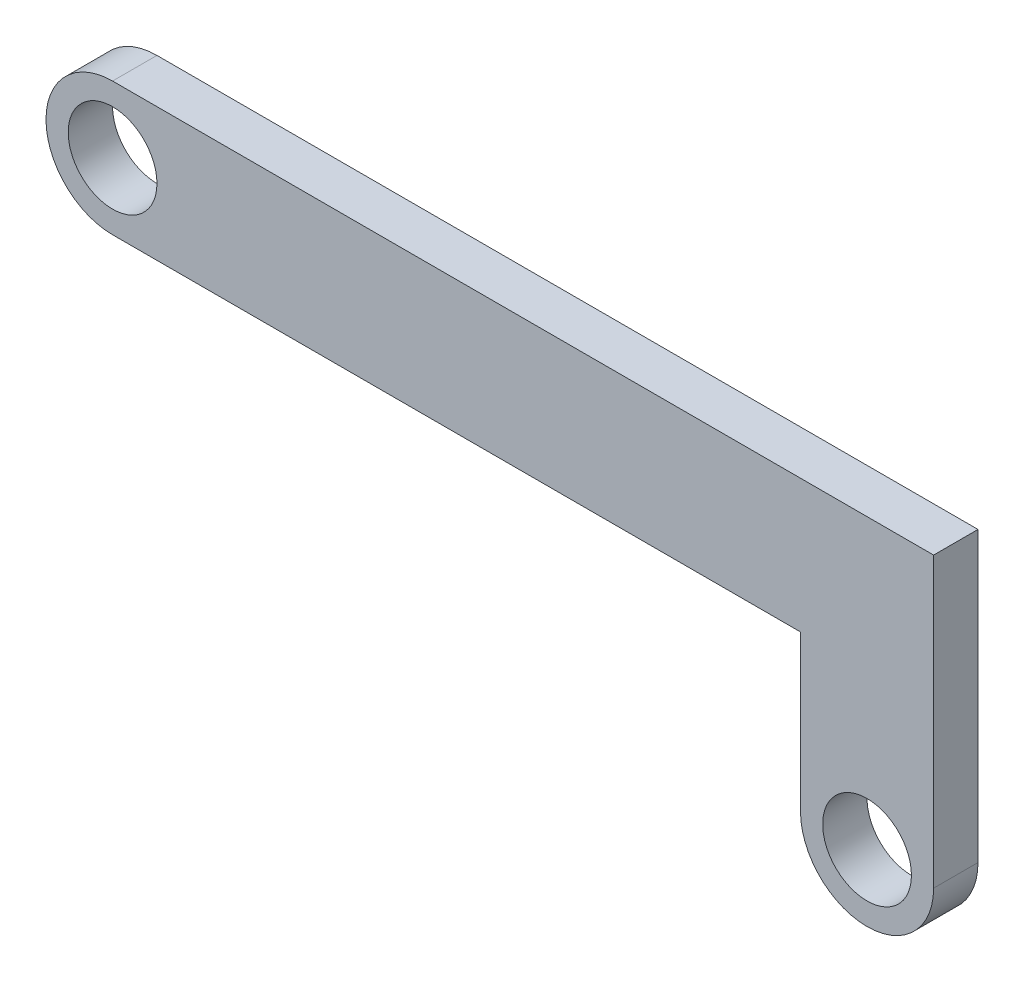
from build123d import *

# Parameters (mm, degrees)
BOSS_EXTRUDE1_DEPTH = 5
SKETCH2_R           = 5
CUT_EXTRUDE1_DEPTH  = 5


with BuildPart() as part:
    # Sketch1 → Boss-Extrude1 (new body)
    with BuildSketch(Plane.XY):
        Polygon((-73.283312465, -1.804635762), (26.716687535, -1.804635762), (26.716687535, -41.804635762), (11.716687535, -41.804635762), (11.716687535, -16.804635762), (-73.283312465, -16.804635762), align=None)
    extrude(amount=BOSS_EXTRUDE1_DEPTH)

    # Sketch2 → Cut-Extrude1 (cut)
    with BuildSketch(Plane.XY.offset(5)):
        with Locations((19.216687535, -34.304635762)):
            Circle(SKETCH2_R)
        with BuildLine():
            ThreePointArc((19.216687535, -41.804635762), (13.913386676, -39.60793662), (11.716687535, -34.304635762))
            Line((11.716687535, -34.304635762), (11.716687535, -41.804635762))
            Line((11.716687535, -41.804635762), (19.216687535, -41.804635762))
        make_face()
        with BuildLine():
            Line((26.716687535, -41.804635762), (26.716687535, -34.304635762))
            ThreePointArc((26.716687535, -34.304635762), (24.519988394, -39.60793662), (19.216687535, -41.804635762))
            Line((19.216687535, -41.804635762), (26.716687535, -41.804635762))
        make_face()
        with Locations((-65.783312465, -9.304635762)):
            Circle(SKETCH2_R)
        with BuildLine():
            Line((-65.783312465, -1.804635762), (-73.283312465, -1.804635762))
            Line((-73.283312465, -1.804635762), (-73.283312465, -9.304635859))
            ThreePointArc((-73.283312465, -9.304635859), (-71.086613359, -4.001334937), (-65.783312465, -1.804635762))
        make_face()
        with BuildLine():
            ThreePointArc((-65.783312465, -16.804635762), (-71.086613289, -14.607936655), (-73.283312465, -9.304635859))
            Line((-73.283312465, -9.304635859), (-73.283312465, -16.804635762))
            Line((-73.283312465, -16.804635762), (-65.783312465, -16.804635762))
        make_face()
    extrude(amount=-CUT_EXTRUDE1_DEPTH, mode=Mode.SUBTRACT)


solid = part.part
